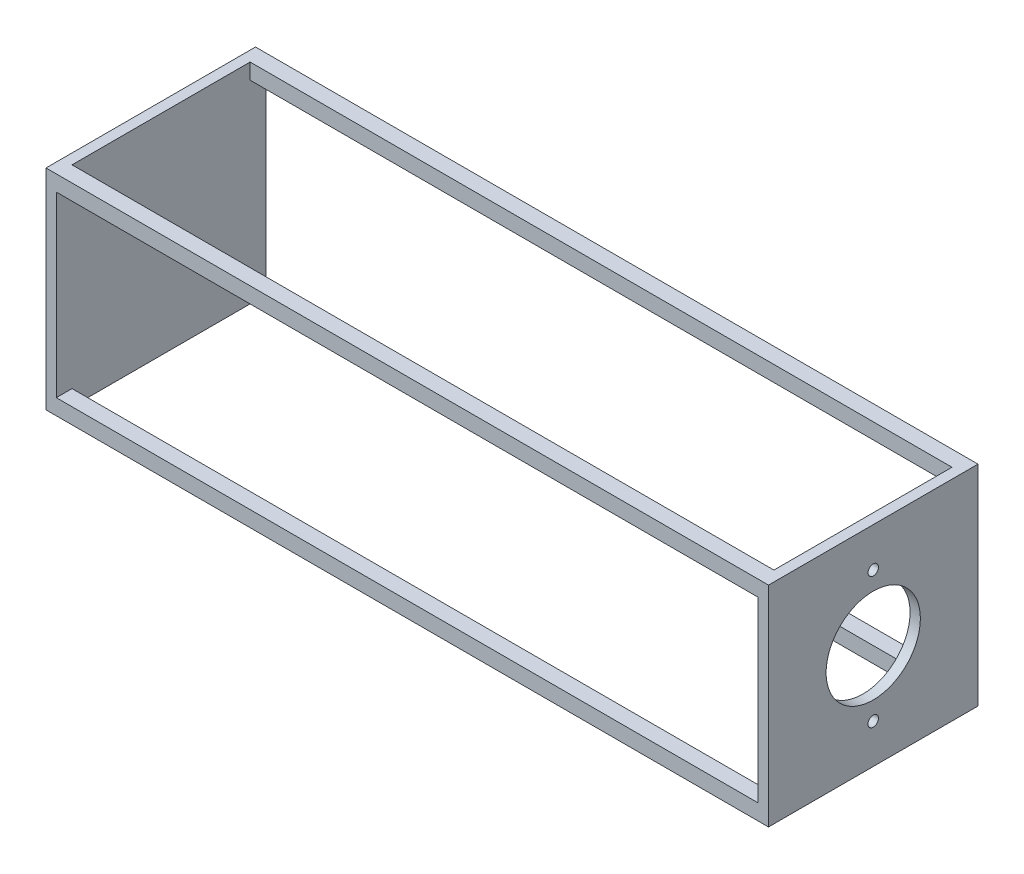
from build123d import *

# Parameters (mm, degrees)
SKETCH2_W           = 175.181977678
SKETCH2_H           = 50.8
BOSS_EXTRUDE1_DEPTH = 25.4
SKETCH8_R           = 11.43
SKETCH8_R_2         = 1.27
CUT_EXTRUDE3_DEPTH  = 12.7
SKETCH10_W          = 170.18
SKETCH10_H          = 43.18
CUT_EXTRUDE5_DEPTH  = 51.8
SKETCH11_R          = 3.175
BOSS_EXTRUDE2_DEPTH = 6.35
CIRPATTERN2_COUNT   = 4
CIRPATTERN3_COUNT   = 2
CIRPATTERN3_ANGLE   = 90


with BuildPart() as part:
    # Sketch2 → Boss-Extrude1 (new body, symmetric)
    with BuildSketch(Plane.XY):
        Rectangle(SKETCH2_W, SKETCH2_H)
    extrude(amount=BOSS_EXTRUDE1_DEPTH, both=True)

    # Sketch8 → Cut-Extrude3 (cut)
    with BuildSketch(Plane(origin=(87.590988839, 0, 0), x_dir=(0, 0, -1), z_dir=(1, 0, 0))):
        Circle(SKETCH8_R)
        with Locations((0, 15.875)):
            Circle(SKETCH8_R_2)
        with Locations((0, -15.875)):
            Circle(SKETCH8_R_2)
    extrude(amount=-CUT_EXTRUDE3_DEPTH, mode=Mode.SUBTRACT)

    # Sketch10 → Cut-Extrude5 (cut, through all)
    with BuildSketch(Plane(origin=(0, 25.4, 0), x_dir=(1, 0, 0), z_dir=(0, 1, 0))):
        Rectangle(SKETCH10_W, SKETCH10_H)
    cut_extrude5 = extrude(amount=-CUT_EXTRUDE5_DEPTH, mode=Mode.SUBTRACT)

    # Sketch11 → Boss-Extrude2 (add)
    with BuildSketch(Plane.ZY.offset(87.590988839)):
        with Locations((0, 12.7)):
            Circle(SKETCH11_R)
    boss_extrude2 = extrude(amount=BOSS_EXTRUDE2_DEPTH)

    # CirPattern2: Boss-Extrude2 ×4 about axis
    cirpattern2_axis = Axis((0, 0, 0), (1, 0, 0))
    for i in range(1, CIRPATTERN2_COUNT):
        add(boss_extrude2.rotate(cirpattern2_axis, i * 360 / CIRPATTERN2_COUNT))

    # CirPattern3: Cut-Extrude5 ×2 about axis
    cirpattern3_axis = Axis((74.890988839, 0, 0), (1, 0, 0))
    for i in range(1, CIRPATTERN3_COUNT):
        add(cut_extrude5.rotate(cirpattern3_axis, i * CIRPATTERN3_ANGLE / (CIRPATTERN3_COUNT - 1)), mode=Mode.SUBTRACT)


solid = part.part
